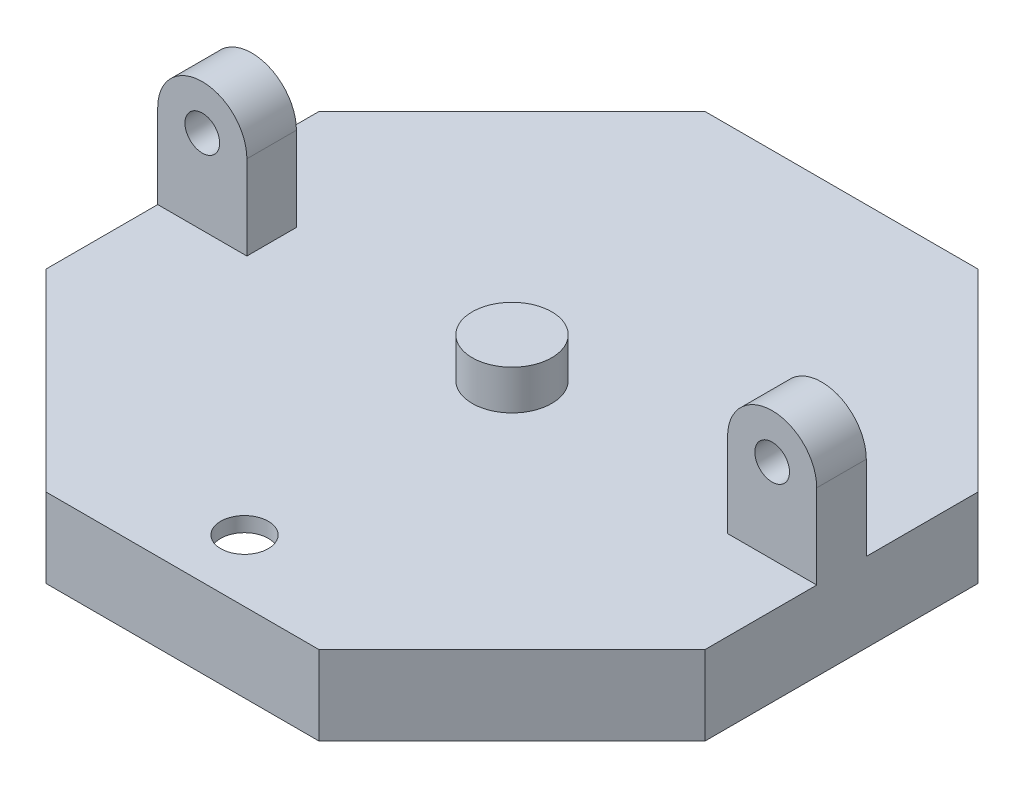
from build123d import *

# Parameters (mm, degrees)
EXTRUDE_1_DEPTH     = 1.5
EXTRUDE_2_DEPTH     = 6.5
CUT_EXTRUDE_1_DEPTH = 1
SKETCH_4_R          = 4.015
EXTRUDE_3_DEPTH     = 4
SKETCH_6_R          = 4.015
EXTRUDE_4_DEPTH     = 4
SKETCH_7_R          = 2.4
CUT_EXTRUDE_3_DEPTH = 48.711742668
SKETCH_8_W          = 9
SKETCH_8_H          = 5
EXTRUDE_5_DEPTH     = 8.5
SKETCH_9_W          = 4.5
SKETCH_9_H          = 5
SKETCH_10_R         = 1.75
CUT_EXTRUDE_4_DEPTH = 51.943190951


with BuildPart() as part:
    # 스케치1 → 보스-돌출1 (new body)
    with BuildSketch(Plane(origin=(0, 0, 0), x_dir=(1, 0, 0), z_dir=(0, 1, 0))):
        Polygon((13.776603565, 33.25966317), (-13.776603565, 33.25966317), (-33.25966317, 13.776603565), (-33.25966317, -13.776603565), (-13.776603565, -33.25966317), (13.776603565, -33.25966317), (33.25966317, -13.776603565), (33.25966317, 13.776603565), align=None)
        Polygon((-13.27954729, 32.05966317), (-32.05966317, 13.27954729), (-32.05966317, -13.27954729), (-13.27954729, -32.05966317), (13.27954729, -32.05966317), (32.05966317, -13.27954729), (32.05966317, 13.27954729), (13.27954729, 32.05966317), align=None, mode=Mode.SUBTRACT)
        Polygon((13.27954729, 32.05966317), (-13.27954729, 32.05966317), (-32.05966317, 13.27954729), (-32.05966317, -13.27954729), (-13.27954729, -32.05966317), (13.27954729, -32.05966317), (32.05966317, -13.27954729), (32.05966317, 13.27954729), align=None)
    extrude(amount=EXTRUDE_1_DEPTH)

    # 스케치2 → 보스-돌출2 (add)
    with BuildSketch(Plane.XZ):
        Polygon((-33.25966317, -13.776603565), (-13.776603565, -33.25966317), (13.776603565, -33.25966317), (33.25966317, -13.776603565), (33.25966317, 13.776603565), (13.776603565, 33.25966317), (-13.776603565, 33.25966317), (-33.25966317, 13.776603565), align=None)
        Polygon((-32.05966317, -13.27954729), (-13.27954729, -32.05966317), (13.27954729, -32.05966317), (32.05966317, -13.27954729), (32.05966317, 13.27954729), (13.27954729, 32.05966317), (-13.27954729, 32.05966317), (-32.05966317, 13.27954729), align=None, mode=Mode.SUBTRACT)
        Polygon((-32.05966317, 13.27954729), (-32.05966317, -13.27954729), (-13.27954729, -32.05966317), (13.27954729, -32.05966317), (32.05966317, -13.27954729), (32.05966317, 13.27954729), (13.27954729, 32.05966317), (-13.27954729, 32.05966317), align=None)
        Polygon((-30.85966317, -12.782491015), (-12.782491015, -30.85966317), (12.782491015, -30.85966317), (30.85966317, -12.782491015), (30.85966317, 12.782491015), (12.782491015, 30.85966317), (-12.782491015, 30.85966317), (-30.85966317, 12.782491015), align=None, mode=Mode.SUBTRACT)
        Polygon((-30.85966317, 12.782491015), (-30.85966317, -12.782491015), (-12.782491015, -30.85966317), (12.782491015, -30.85966317), (30.85966317, -12.782491015), (30.85966317, 12.782491015), (12.782491015, 30.85966317), (-12.782491015, 30.85966317), align=None)
        Polygon((-29.65966317, -12.285434741), (-12.285434741, -29.65966317), (12.285434741, -29.65966317), (29.65966317, -12.285434741), (29.65966317, 12.285434741), (12.285434741, 29.65966317), (-12.285434741, 29.65966317), (-29.65966317, 12.285434741), align=None, mode=Mode.SUBTRACT)
    extrude(amount=EXTRUDE_2_DEPTH)

    # 스케치3 → 컷-돌출1 (cut)
    with BuildSketch(Plane.XZ.offset(6.5)):
        Polygon((-32.05966317, -13.27954729), (-13.27954729, -32.05966317), (13.27954729, -32.05966317), (32.05966317, -13.27954729), (32.05966317, 13.27954729), (13.27954729, 32.05966317), (-13.27954729, 32.05966317), (-32.05966317, 13.27954729), align=None)
        Polygon((-30.85966317, -12.782491015), (-12.782491015, -30.85966317), (12.782491015, -30.85966317), (30.85966317, -12.782491015), (30.85966317, 12.782491015), (12.782491015, 30.85966317), (-12.782491015, 30.85966317), (-30.85966317, 12.782491015), align=None, mode=Mode.SUBTRACT)
    extrude(amount=-CUT_EXTRUDE_1_DEPTH, mode=Mode.SUBTRACT)

    # 스케치4 → 보스-돌출3 (add)
    with BuildSketch(Plane(origin=(0, 1.5, 0), x_dir=(1, 0, 0), z_dir=(0, 1, 0))):
        with Locations(Location((0, 0, 0), (0, 0, 270))):
            Circle(SKETCH_4_R)
    extrude(amount=EXTRUDE_3_DEPTH)

    # 스케치6 → 보스-돌출4 (add)
    with BuildSketch(Plane.XZ):
        with Locations(Location((0, 0, 0), (0, 0, 90))):
            Circle(SKETCH_6_R)
    extrude(amount=EXTRUDE_4_DEPTH)

    # 스케치7 → 컷-돌출3 (cut, through all)
    with BuildSketch(Plane(origin=(0, 1.5, 0), x_dir=(1, 0, 0), z_dir=(0, 1, 0))):
        with Locations(Location((0, -27, 0), (0, 0, 270))):
            Circle(SKETCH_7_R)
    extrude(amount=-CUT_EXTRUDE_3_DEPTH, mode=Mode.SUBTRACT)

    # 스케치8 → 보스-돌출5 (add)
    with BuildSketch(Plane(origin=(0, 1.5, 0), x_dir=(1, 0, 0), z_dir=(0, 1, 0))):
        with Locations((-28.75966317, 0)):
            Rectangle(SKETCH_8_W, SKETCH_8_H)
    extrude_5 = extrude(amount=EXTRUDE_5_DEPTH)

    # 스케치9 → 회전1 (revolve)
    with BuildSketch(Plane(origin=(0, 10, 0), x_dir=(1, 0, 0), z_dir=(0, 1, 0))):
        with Locations((-31.00966317, 0)):
            Rectangle(SKETCH_9_W, SKETCH_9_H)
    revolve_1 = revolve(axis=Axis((-28.75966317, 10, -5.508751215), (0, 0, 1)))

    # 스케치10 → 컷-돌출4 (cut, through all)
    with BuildSketch(Plane.XY.offset(2.5)):
        with Locations((-28.75966317, 10)):
            Circle(SKETCH_10_R)
    cut_extrude_4 = extrude(amount=-CUT_EXTRUDE_4_DEPTH, mode=Mode.SUBTRACT)

    # 대칭 복사1: 보스-돌출5, 회전1, 컷-돌출4 across plane
    add(extrude_5.mirror(Plane(origin=(0, 0, 0), x_dir=(0, 0, 1), z_dir=(1, 0, 0))))
    add(revolve_1.mirror(Plane(origin=(0, 0, 0), x_dir=(0, 0, 1), z_dir=(1, 0, 0))))
    add(cut_extrude_4.mirror(Plane(origin=(0, 0, 0), x_dir=(0, 0, 1), z_dir=(1, 0, 0))), mode=Mode.SUBTRACT)


solid = part.part
